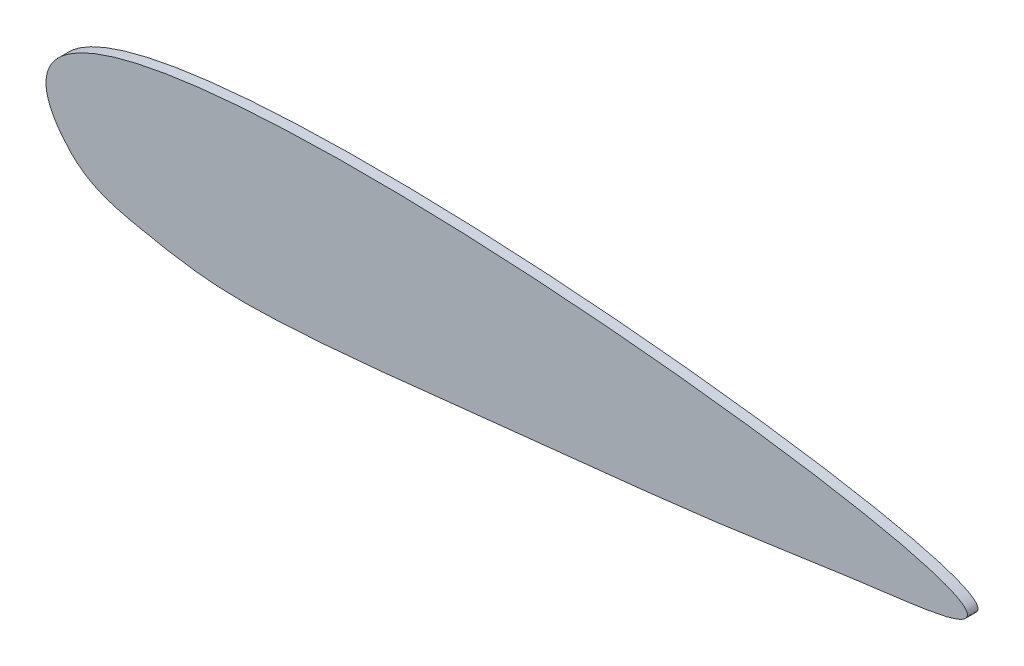
from build123d import *

# Parameters (mm, degrees)
EXTRUDE_1_DEPTH = 3


with BuildPart() as part:
    # ｽｹｯﾁ1 → ﾎﾞｽ - 押し出し1 (new body)
    with BuildSketch(Plane.XY):
        with BuildLine():
            add(Edge.make_bspline(
                [(0, 0), (1.346818436, -1.774316354), (7.607621803, -8.726330935), (23.044325036, -12.229189562), (42.796567803, -15.805972005), (75.809638704, -14.887195625), (125.053187111, -8.825293871), (181.635220322, -3.563471139), (222.051389355, 2.980425951), (341.127697081, 16.768188922), (-47.478291998, 62.5485275), (0, 0)],
                knots=[0, 0, 0, 0, 0.014045153, 0.052533118, 0.09025551, 0.134135357, 0.24712661, 0.387170902, 0.463989086, 0.504877679, 1, 1, 1, 1], degree=3))
        make_face()
    extrude(amount=EXTRUDE_1_DEPTH)


solid = part.part
